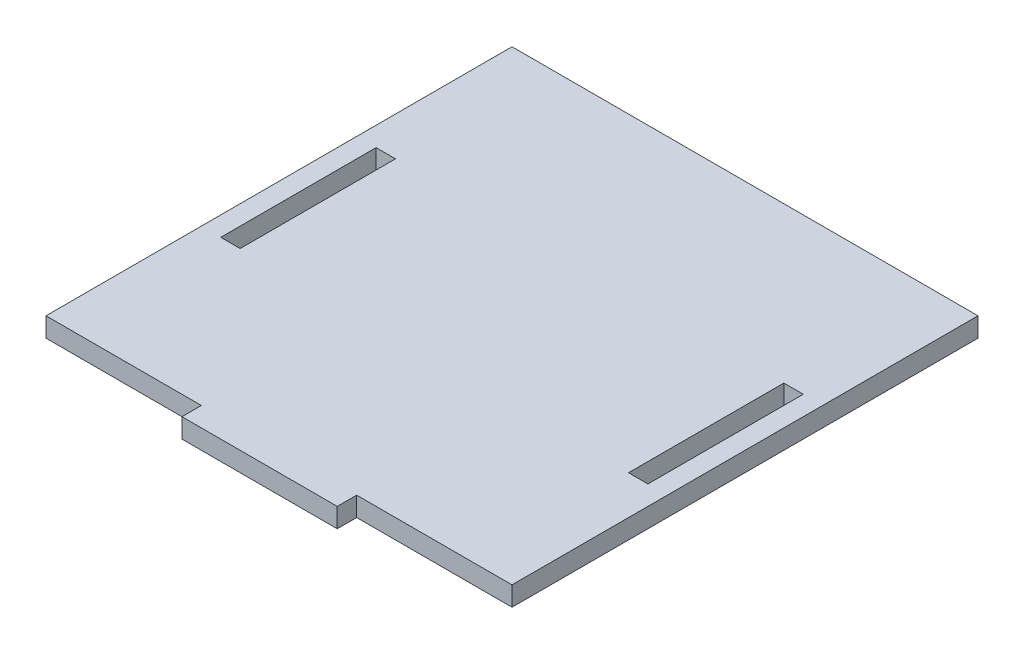
from build123d import *

# Parameters (mm, degrees)
SKETCH1_W           = 6.35
SKETCH1_H           = 50.8
BOSS_EXTRUDE1_DEPTH = 6.35


with BuildPart() as part:
    # Sketch1 → Boss-Extrude1 (new body)
    with BuildSketch(Plane(origin=(0, 0, 0), x_dir=(1, 0, 0), z_dir=(0, 1, 0))):
        Polygon((-25.4, -79.375), (25.4, -79.375), (25.4, -73.025), (76.2, -73.025), (76.2, 79.375), (-76.2, 79.375), (-76.2, -73.025), (-25.4, -73.025), align=None)
        with Locations((-66.675, 3.175)):
            Rectangle(SKETCH1_W, SKETCH1_H, mode=Mode.SUBTRACT)
        with Locations((66.675, 3.175)):
            Rectangle(SKETCH1_W, SKETCH1_H, mode=Mode.SUBTRACT)
    extrude(amount=BOSS_EXTRUDE1_DEPTH)


solid = part.part
